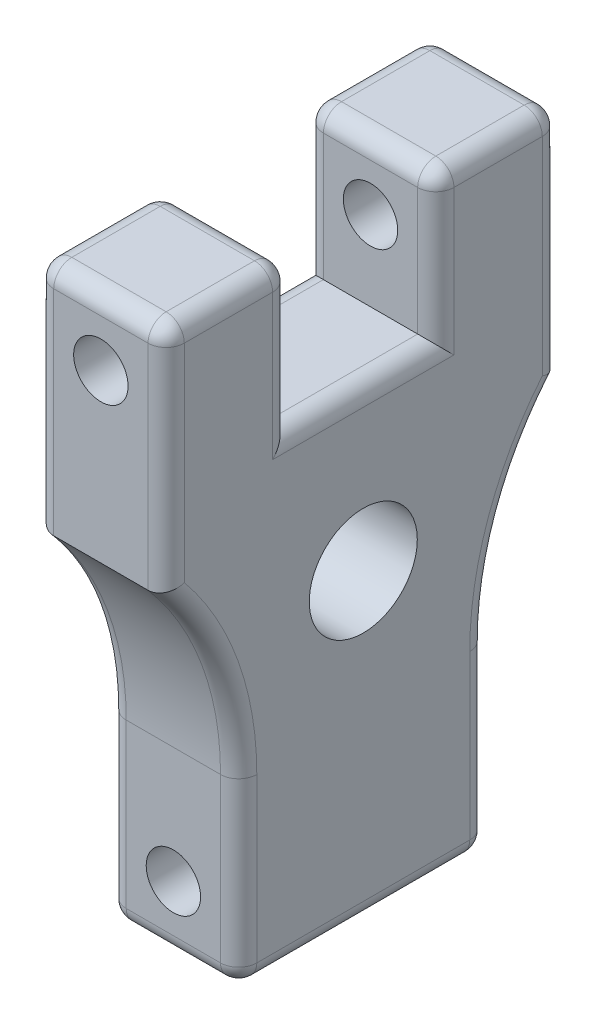
from build123d import *

# Parameters (mm, degrees)
BOSS_EXTRUDE1_DEPTH = 22.86
SKETCH2_R           = 4.7625
CUT_EXTRUDE1_DEPTH  = 70.0372
SKETCH3_R           = 9.4615
CUT_EXTRUDE2_DEPTH  = 23.86
FILLET1_R           = 3.175


with BuildPart() as part:
    # Sketch1 → Boss-Extrude1 (new body)
    with BuildSketch(Plane(origin=(0, 0, 0), x_dir=(0, 0, -1), z_dir=(1, 0, 0))):
        with BuildLine():
            Line((43.6372, 0), (43.6372, 31.75))
            ThreePointArc((43.6372, 31.75), (46.914198612, 50.033148662), (56.3372, 66.04))
            Line((56.3372, 66.04), (56.3372, 106.68))
            Line((56.3372, 106.68), (34.5186, 106.68))
            Line((34.5186, 106.68), (34.5186, 81.28))
            Line((34.5186, 81.28), (9.1186, 81.28))
            Line((9.1186, 81.28), (9.1186, 106.68))
            Line((9.1186, 106.68), (-12.7, 106.68))
            Line((-12.7, 106.68), (-12.7, 66.04))
            ThreePointArc((-12.7, 66.04), (-3.276998612, 50.033148662), (0, 31.75))
            Line((0, 31.75), (0, 0))
            Line((0, 0), (43.6372, 0))
        make_face()
    extrude(amount=BOSS_EXTRUDE1_DEPTH)

    # Sketch2 → Cut-Extrude1 (cut, through all)
    with BuildSketch(Plane.XY.offset(12.7)):
        with Locations((11.43, 95.25)):
            Circle(SKETCH2_R)
        with Locations((11.43, 11.43)):
            Circle(SKETCH2_R)
    extrude(amount=-CUT_EXTRUDE1_DEPTH, mode=Mode.SUBTRACT)

    # Sketch3 → Cut-Extrude2 (cut, through all)
    with BuildSketch(Plane(origin=(22.86, 0, 0), x_dir=(0, 0, -1), z_dir=(1, 0, 0))):
        with Locations((21.8186, 53.34)):
            Circle(SKETCH3_R)
    extrude(amount=-CUT_EXTRUDE2_DEPTH, mode=Mode.SUBTRACT)

    # Fillet1
    fillet1_edges = [part.edges().sort_by_distance(p)[0] for p in [
        (22.86, 50.033148662, -46.914198612),
        (0, 15.875, 0),
        (0, 50.033148662, 3.276998612),
        (0, 86.36, 12.7),
        (0, 106.68, 1.7907),
        (0, 93.98, -9.1186),
        (0, 81.28, -21.8186),
        (22.86, 86.36, -56.3372),
        (0, 93.98, -34.5186),
        (0, 106.68, -45.4279),
        (0, 86.36, -56.3372),
        (0, 50.033148662, -46.914198612),
        (0, 15.875, -43.6372),
        (0, 0, -21.8186),
        (22.86, 106.68, -45.4279),
        (22.86, 93.98, -34.5186),
        (11.43, 0, 0),
        (11.43, 106.68, 12.7),
        (11.43, 106.68, -9.1186),
        (11.43, 106.68, -34.5186),
        (11.43, 106.68, -56.3372),
        (11.43, 0, -43.6372),
        (22.86, 81.28, -21.8186),
        (22.86, 93.98, -9.1186),
        (22.86, 106.68, 1.7907),
        (22.86, 86.36, 12.7),
        (22.86, 50.033148662, 3.276998612),
        (22.86, 15.875, 0),
        (22.86, 0, -21.8186),
        (22.86, 15.875, -43.6372),
    ]]
    fillet(fillet1_edges, radius=FILLET1_R)


solid = part.part
